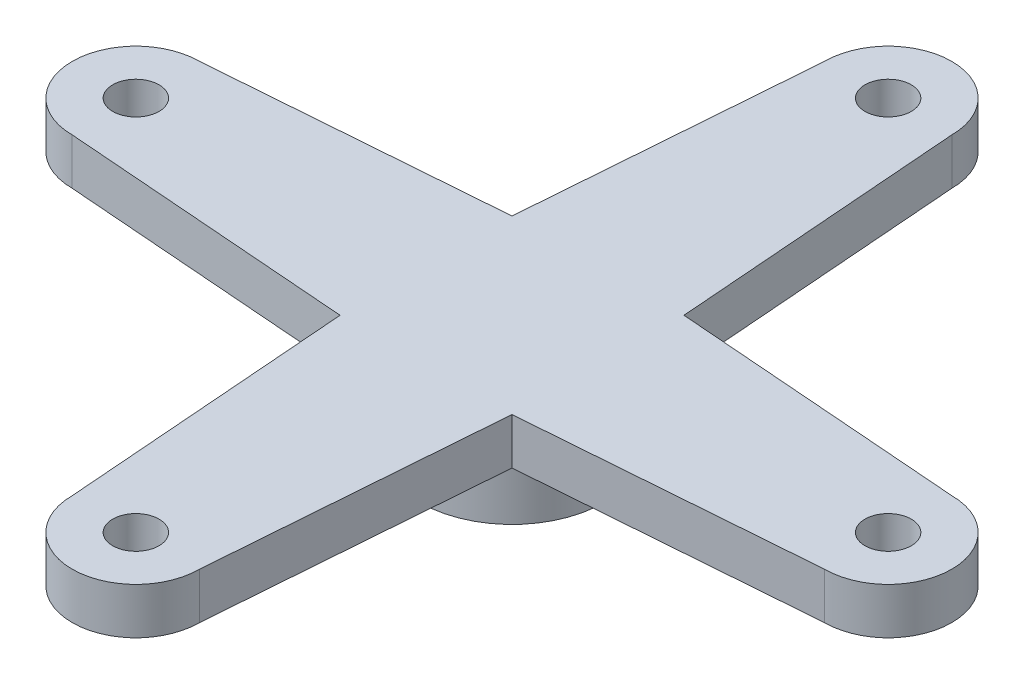
from build123d import *

# Parameters (mm, degrees)
SKETCH1_R           = 4
BOSS_EXTRUDE1_DEPTH = 3
SKETCH2_R           = 1
BOSS_EXTRUDE3_DEPTH = 2


with BuildPart() as part:
    # Sketch1 → Boss-Extrude1 (new body)
    with BuildSketch(Plane(origin=(0, 0, 0), x_dir=(1, 0, 0), z_dir=(0, 1, 0))):
        Circle(SKETCH1_R)
    extrude(amount=BOSS_EXTRUDE1_DEPTH)


with BuildPart() as body_2:
    # Sketch2 → Boss-Extrude3 (new body)
    with BuildSketch(Plane(origin=(0, 3, 0), x_dir=(1, 0, 0), z_dir=(0, 1, 0))):
        with BuildLine():
            Line((16.25, 2.75), (3.714285714, 3.714285714))
            Line((3.714285714, 3.714285714), (2.75, 16.25))
            ThreePointArc((2.75, 16.25), (0, 19), (-2.75, 16.25))
            Line((-2.75, 16.25), (-3.714285714, 3.714285714))
            Line((-3.714285714, 3.714285714), (-16.25, 2.75))
            ThreePointArc((-16.25, 2.75), (-19, 0), (-16.25, -2.75))
            Line((-16.25, -2.75), (-3.714285714, -3.714285714))
            Line((-3.714285714, -3.714285714), (-2.75, -16.25))
            ThreePointArc((-2.75, -16.25), (0, -19), (2.75, -16.25))
            Line((2.75, -16.25), (3.714285714, -3.714285714))
            Line((3.714285714, -3.714285714), (16.25, -2.75))
            ThreePointArc((16.25, -2.75), (19, 0), (16.25, 2.75))
        make_face()
        with Locations((16.25, 0)):
            Circle(SKETCH2_R, mode=Mode.SUBTRACT)
        with Locations((0, 16.25)):
            Circle(SKETCH2_R, mode=Mode.SUBTRACT)
        with Locations((0, -16.25)):
            Circle(SKETCH2_R, mode=Mode.SUBTRACT)
        with Locations((-16.25, 0)):
            Circle(SKETCH2_R, mode=Mode.SUBTRACT)
    extrude(amount=BOSS_EXTRUDE3_DEPTH)


solid = Compound([part.part, body_2.part])
